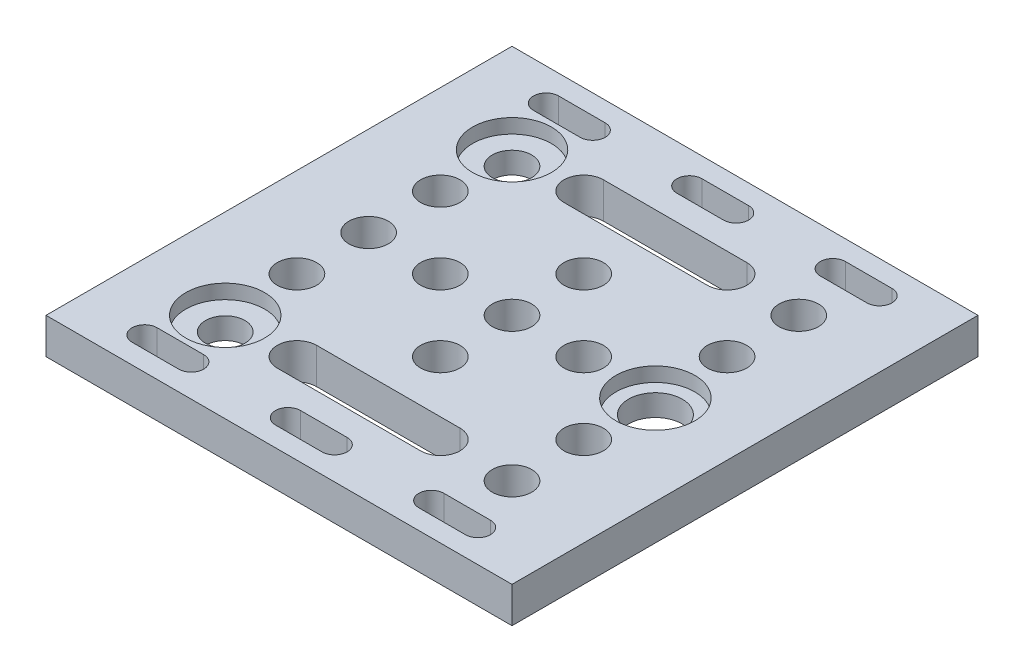
from build123d import *

# Parameters (mm, degrees)
SKETCH1_W           = 65
SKETCH1_H           = 65
SKETCH1_R           = 2.75
SKETCH1_R_2         = 3.75
BOSS_EXTRUDE1_DEPTH = 5
SKETCH2_R           = 5.5
CUT_EXTRUDE1_DEPTH  = 2


with BuildPart() as part:
    # Sketch1 → Boss-Extrude1 (new body)
    with BuildSketch(Plane(origin=(0, 0, 0), x_dir=(1, 0, 0), z_dir=(0, 1, 0))):
        with Locations((32.5, 32.5)):
            Rectangle(SKETCH1_W, SKETCH1_H)
        with Locations((32.5, 32.5)):
            Circle(SKETCH1_R, mode=Mode.SUBTRACT)
        with Locations((22.5, 32.5)):
            Circle(SKETCH1_R, mode=Mode.SUBTRACT)
        with Locations((12.5, 32.5)):
            Circle(SKETCH1_R, mode=Mode.SUBTRACT)
        with Locations((32.5, 42.5)):
            Circle(SKETCH1_R, mode=Mode.SUBTRACT)
        with Locations((12.5, 42.5)):
            Circle(SKETCH1_R, mode=Mode.SUBTRACT)
        with Locations((12.5, 52.5)):
            Circle(SKETCH1_R, mode=Mode.SUBTRACT)
        with Locations((42.5, 32.5)):
            Circle(SKETCH1_R, mode=Mode.SUBTRACT)
        with Locations((52.5, 32.5)):
            Circle(SKETCH1_R_2, mode=Mode.SUBTRACT)
        with Locations((52.5, 42.5)):
            Circle(SKETCH1_R, mode=Mode.SUBTRACT)
        with Locations((52.5, 22.5)):
            Circle(SKETCH1_R, mode=Mode.SUBTRACT)
        with Locations((32.5, 22.5)):
            Circle(SKETCH1_R, mode=Mode.SUBTRACT)
        with Locations((12.5, 22.5)):
            Circle(SKETCH1_R, mode=Mode.SUBTRACT)
        with Locations((12.5, 12.5)):
            Circle(SKETCH1_R, mode=Mode.SUBTRACT)
        with Locations((52.5, 52.5)):
            Circle(SKETCH1_R, mode=Mode.SUBTRACT)
        with Locations((52.5, 12.5)):
            Circle(SKETCH1_R, mode=Mode.SUBTRACT)
        with BuildLine():
            Line((22.5, 55.25), (42.5, 55.25))
            ThreePointArc((42.5, 55.25), (45.25, 52.5), (42.5, 49.75))
            Line((42.5, 49.75), (22.5, 49.75))
            ThreePointArc((22.5, 49.75), (19.75, 52.5), (22.5, 55.25))
        make_face(mode=Mode.SUBTRACT)
        with BuildLine():
            Line((29.25, 62.25), (35.75, 62.25))
            ThreePointArc((35.75, 62.25), (37.5, 60.5), (35.75, 58.75))
            Line((35.75, 58.75), (29.25, 58.75))
            ThreePointArc((29.25, 58.75), (27.5, 60.5), (29.25, 62.25))
        make_face(mode=Mode.SUBTRACT)
        with BuildLine():
            Line((9.25, 62.25), (15.75, 62.25))
            ThreePointArc((15.75, 62.25), (17.5, 60.5), (15.75, 58.75))
            Line((15.75, 58.75), (9.25, 58.75))
            ThreePointArc((9.25, 58.75), (7.5, 60.5), (9.25, 62.25))
        make_face(mode=Mode.SUBTRACT)
        with BuildLine():
            Line((55.75, 62.25), (49.25, 62.25))
            ThreePointArc((49.25, 62.25), (47.5, 60.5), (49.25, 58.75))
            Line((49.25, 58.75), (55.75, 58.75))
            ThreePointArc((55.75, 58.75), (57.5, 60.5), (55.75, 62.25))
        make_face(mode=Mode.SUBTRACT)
        with BuildLine():
            Line((22.5, 9.75), (42.5, 9.75))
            ThreePointArc((42.5, 9.75), (45.25, 12.5), (42.5, 15.25))
            Line((42.5, 15.25), (22.5, 15.25))
            ThreePointArc((22.5, 15.25), (19.75, 12.5), (22.5, 9.75))
        make_face(mode=Mode.SUBTRACT)
        with BuildLine():
            Line((55.75, 2.75), (49.25, 2.75))
            ThreePointArc((49.25, 2.75), (47.5, 4.5), (49.25, 6.25))
            Line((49.25, 6.25), (55.75, 6.25))
            ThreePointArc((55.75, 6.25), (57.5, 4.5), (55.75, 2.75))
        make_face(mode=Mode.SUBTRACT)
        with BuildLine():
            Line((9.25, 2.75), (15.75, 2.75))
            ThreePointArc((15.75, 2.75), (17.5, 4.5), (15.75, 6.25))
            Line((15.75, 6.25), (9.25, 6.25))
            ThreePointArc((9.25, 6.25), (7.5, 4.5), (9.25, 2.75))
        make_face(mode=Mode.SUBTRACT)
        with BuildLine():
            Line((29.25, 2.75), (35.75, 2.75))
            ThreePointArc((35.75, 2.75), (37.5, 4.5), (35.75, 6.25))
            Line((35.75, 6.25), (29.25, 6.25))
            ThreePointArc((29.25, 6.25), (27.5, 4.5), (29.25, 2.75))
        make_face(mode=Mode.SUBTRACT)
    extrude(amount=BOSS_EXTRUDE1_DEPTH)

    # Sketch2 → Cut-Extrude1 (cut)
    with BuildSketch(Plane(origin=(0, 5, 0), x_dir=(1, 0, 0), z_dir=(0, 1, 0))):
        with Locations((12.5, 52.5)):
            Circle(SKETCH2_R)
        with Locations((52.5, 32.5)):
            Circle(SKETCH2_R)
        with Locations((12.5, 12.5)):
            Circle(SKETCH2_R)
    extrude(amount=-CUT_EXTRUDE1_DEPTH, mode=Mode.SUBTRACT)


solid = part.part
